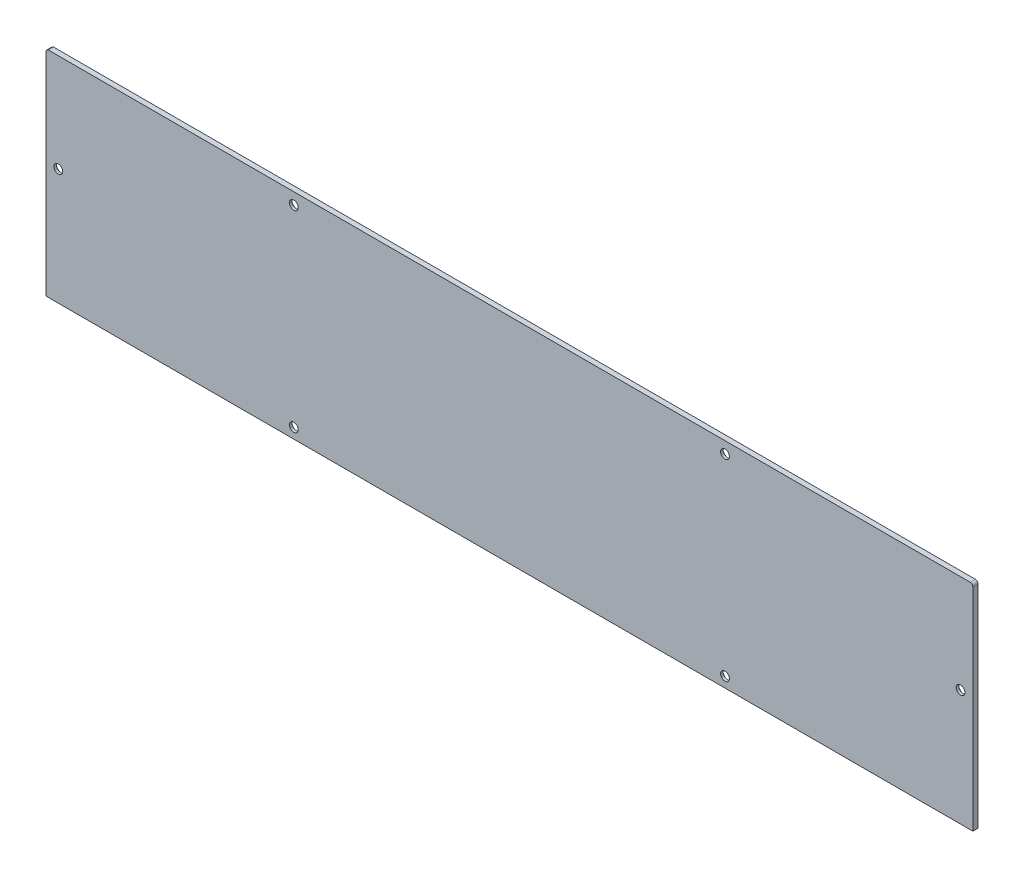
from build123d import *

# Parameters (mm, degrees)
EXTRUDE_1_DEPTH            = 2
HOLE_WIZARD_2_D            = 3.4
HOLE_WIZARD_2_DEPTH        = 7.5
HOLE_WIZARD_2_CBORE_D      = 6
HOLE_WIZARD_2_CBORE_DEPTH  = 1
HOLE_WIZARD_2_TIP          = 1.021463052
CUT_EXTRUDE_1_DEPTH        = 3
HOLE_WIZARD_2_2_AT_2_COUNT = 2
HOLE_WIZARD_2_2_AT_2_PITCH = 167
EXTRUDE_3_DEPTH            = 2


with BuildPart() as part:
    # 草图1 → 凸台-拉伸1 (new body)
    with BuildSketch(Plane(origin=(0, 0, 222.724508868), x_dir=(-1, 0, 0), z_dir=(0, 0, -1))):
        with BuildLine():
            Line((-76.251869293, -10), (282.750233779, -10))
            Line((282.750233779, -10), (282.750233779, 70))
            ThreePointArc((282.750233779, 70), (281.871554123, 72.121320344), (279.750233779, 73))
            Line((279.750233779, 73), (-73.251869293, 73))
            ThreePointArc((-73.251869293, 73), (-75.373189637, 72.121320344), (-76.251869293, 70))
            Line((-76.251869293, 70), (-76.251869293, -10))
        make_face()
    extrude(amount=EXTRUDE_1_DEPTH)

    # Hole Wizard 2
    with Locations(Plane(origin=(71.501869293, 35, 220.724508868), x_dir=(-1, 0, 0), z_dir=(0, 0, -1))):
        with Locations((0, 0), (91.251051536, 33.5), (258.251051536, 33.5), (349.502103072, 0)):
            CounterBoreHole(HOLE_WIZARD_2_D / 2, HOLE_WIZARD_2_CBORE_D / 2, HOLE_WIZARD_2_CBORE_DEPTH, depth=HOLE_WIZARD_2_DEPTH)
            with Locations((0, 0, -(HOLE_WIZARD_2_DEPTH + HOLE_WIZARD_2_TIP / 2))):  # 118° drill point
                Cone(0, HOLE_WIZARD_2_D / 2, HOLE_WIZARD_2_TIP, mode=Mode.SUBTRACT)

    # 草图4 → 切除-拉伸1 (cut, through all)
    with BuildSketch(Plane(origin=(0, 0, 220.724508868), x_dir=(-1, 0, 0), z_dir=(0, 0, -1))):
        with BuildLine():
            Line((-76.251869293, 70), (-76.251869293, -10))
            Line((-76.251869293, -10), (-75.751869293, -10))
            Line((-75.751869293, -10), (-75.751869293, 70))
            ThreePointArc((-75.751869293, 70), (-75.019636246, 71.767766953), (-73.251869293, 72.5))
            Line((-73.251869293, 72.5), (279.750233779, 72.5))
            ThreePointArc((279.750233779, 72.5), (281.518000732, 71.767766953), (282.250233779, 70))
            Line((282.250233779, 70), (282.250233779, -10))
            Line((282.250233779, -10), (282.750233779, -10))
            Line((282.750233779, -10), (282.750233779, 70))
            ThreePointArc((282.750233779, 70), (281.871554123, 72.121320344), (279.750233779, 73))
            Line((279.750233779, 73), (-73.251869293, 73))
            ThreePointArc((-73.251869293, 73), (-75.373189637, 72.121320344), (-76.251869293, 70))
        make_face()
    extrude(amount=-CUT_EXTRUDE_1_DEPTH, mode=Mode.SUBTRACT)

    # 草图5 → Hole Wizard 2 2 (revolve, cut)
    with BuildSketch(Plane(origin=(-19.749182243, -6, 220.724508868), x_dir=(0, 1, 0), z_dir=(1, 0, 0))):
        Polygon((0, 0), (0, 20.521463052), (1.7, 19.5), (1.7, 1), (3, 1), (3, 0), align=None)
    hole_wizard_2_2 = revolve(axis=Axis((-19.749182243, -6, 214.374508868), (0, 0, 1)), mode=Mode.SUBTRACT)

    # Hole Wizard 2 2 at 2: Hole Wizard 2 2 ×2
    with Locations(*[(-i * HOLE_WIZARD_2_2_AT_2_PITCH, 0, 0) for i in range(1, HOLE_WIZARD_2_2_AT_2_COUNT)]):
        add(hole_wizard_2_2, mode=Mode.SUBTRACT)

    # 草图6 → 凸台-拉伸3 (add)
    with BuildSketch(Plane(origin=(0, 0, 220.724508868), x_dir=(-1, 0, 0), z_dir=(0, 0, -1))):
        with BuildLine():
            Line((-76.251869293, 72), (-76.251869293, -10))
            Line((-76.251869293, -10), (-75.751869293, -10))
            Line((-75.751869293, -10), (-75.751869293, 70))
            ThreePointArc((-75.751869293, 70), (-75.019636246, 71.767766953), (-73.251869293, 72.5))
            Line((-73.251869293, 72.5), (279.750233779, 72.5))
            ThreePointArc((279.750233779, 72.5), (281.518000732, 71.767766953), (282.250233779, 70))
            Line((282.250233779, 70), (282.250233779, -10))
            Line((282.250233779, -10), (282.750233779, -10))
            Line((282.750233779, -10), (282.750233779, 72))
            ThreePointArc((282.750233779, 72), (282.457340561, 72.707106781), (281.750233779, 73))
            Line((281.750233779, 73), (-75.251869293, 73))
            ThreePointArc((-75.251869293, 73), (-75.958976075, 72.707106781), (-76.251869293, 72))
        make_face()
    extrude(amount=-EXTRUDE_3_DEPTH)


solid = part.part
